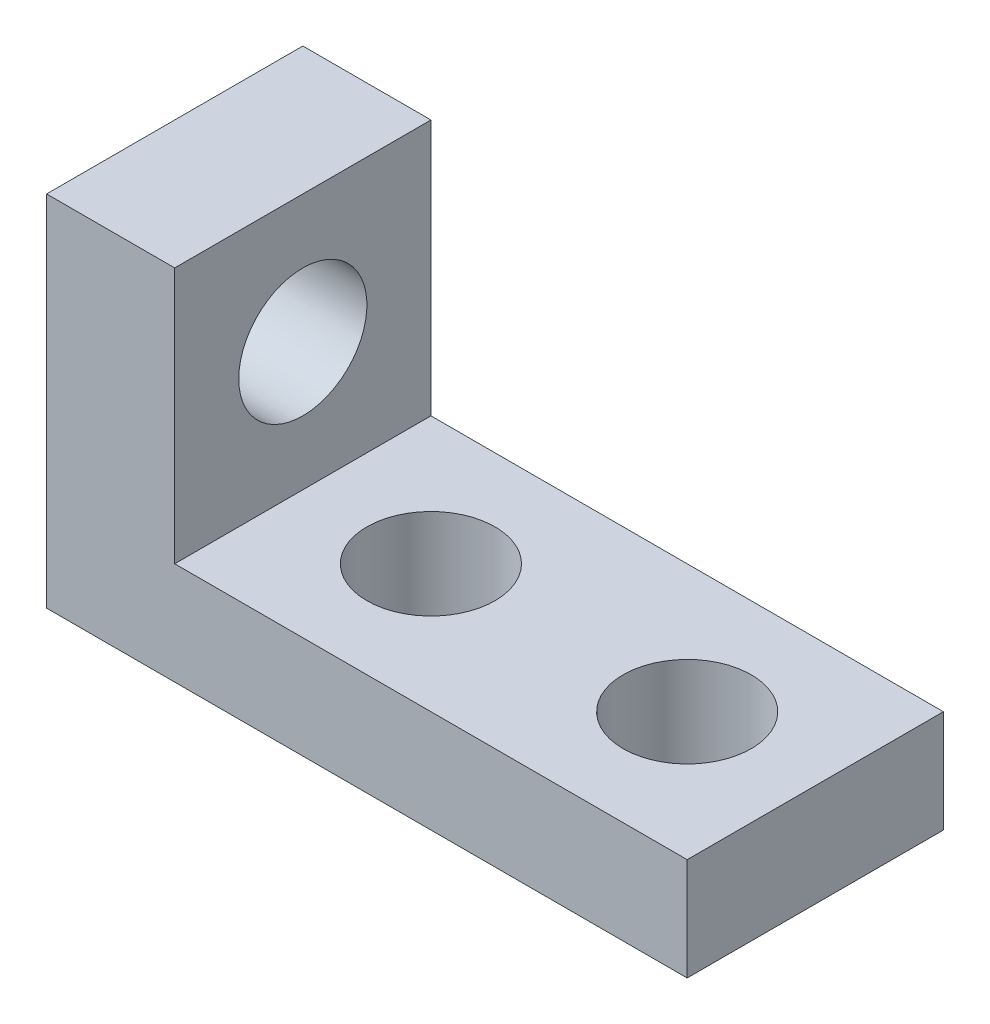
from build123d import *

# Parameters (mm, degrees)
SKETCH1_W           = 12.7
SKETCH1_H           = 6.35
SKETCH1_R           = 1.5875
BOSS_EXTRUDE1_DEPTH = 2.54
SKETCH2_W           = 6.35
SKETCH2_H           = 8.89
SKETCH2_R           = 1.5875
BOSS_EXTRUDE2_DEPTH = 3.175


with BuildPart() as part:
    # Sketch1 → Boss-Extrude1 (new body)
    with BuildSketch(Plane(origin=(0, 0, 0), x_dir=(1, 0, 0), z_dir=(0, 1, 0))):
        with Locations((-6.35, 3.175)):
            Rectangle(SKETCH1_W, SKETCH1_H)
        with Locations((-3.175, 3.175)):
            Circle(SKETCH1_R, mode=Mode.SUBTRACT)
        with Locations((-9.525, 3.175)):
            Circle(SKETCH1_R, mode=Mode.SUBTRACT)
    extrude(amount=BOSS_EXTRUDE1_DEPTH)

    # Sketch2 → Boss-Extrude2 (add)
    with BuildSketch(Plane.ZY.offset(12.7)):
        with Locations((-3.175, 4.445)):
            Rectangle(SKETCH2_W, SKETCH2_H)
        with Locations((-3.175, 5.715)):
            Circle(SKETCH2_R, mode=Mode.SUBTRACT)
    extrude(amount=BOSS_EXTRUDE2_DEPTH)


solid = part.part
